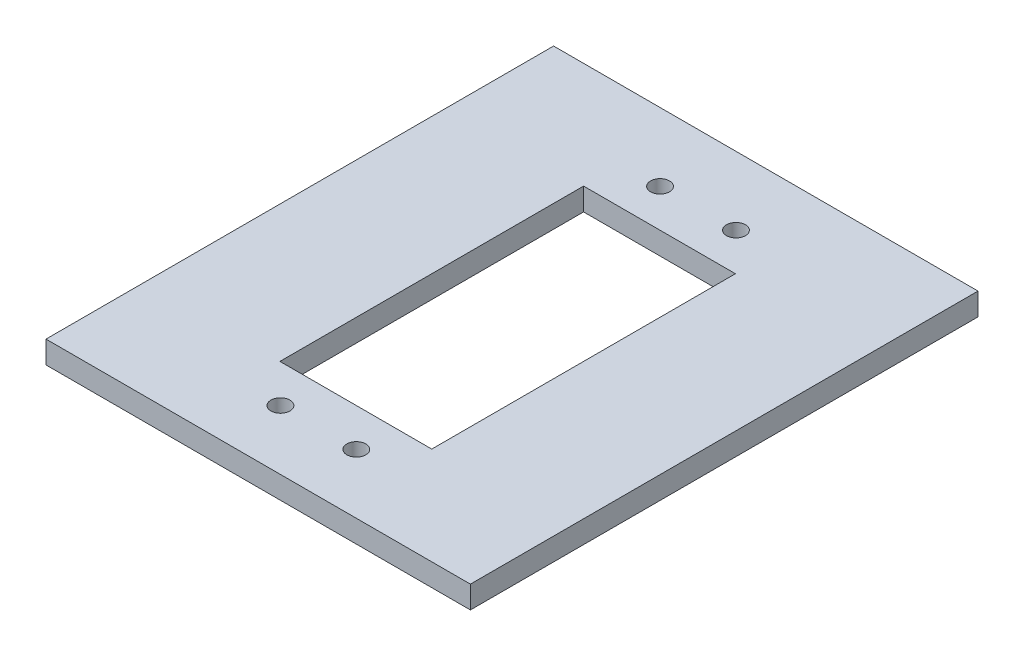
from build123d import *

# Parameters (mm, degrees)
SKETCH1_W           = 55.9
SKETCH1_H           = 66.86
BOSS_EXTRUDE1_DEPTH = 2.95
SKETCH3_W           = 20
SKETCH3_H           = 40
CUT_EXTRUDE1_DEPTH  = 6.86
SKETCH4_R           = 1.25
CUT_EXTRUDE2_DEPTH  = 6.86


with BuildPart() as part:
    # Sketch1 → Boss-Extrude1 (new body)
    with BuildSketch(Plane(origin=(0, 0, 0), x_dir=(1, 0, 0), z_dir=(0, 1, 0))):
        with Locations((3.202267267, 0.752730799)):
            Rectangle(SKETCH1_W, SKETCH1_H)
    extrude(amount=BOSS_EXTRUDE1_DEPTH)

    # Sketch3 → Cut-Extrude1 (cut)
    with BuildSketch(Plane(origin=(0, 2.95, 0), x_dir=(1, 0, 0), z_dir=(0, 1, 0))):
        with Locations((3.202267267, 0.182730799)):
            Rectangle(SKETCH3_W, SKETCH3_H)
    extrude(amount=-CUT_EXTRUDE1_DEPTH, mode=Mode.SUBTRACT)

    # Sketch4 → Cut-Extrude2 (cut)
    with BuildSketch(Plane(origin=(0, 2.95, 0), x_dir=(1, 0, 0), z_dir=(0, 1, 0))):
        with Locations((-1.729576987, 25.182730799)):
            Circle(SKETCH4_R)
        with Locations((8.270423013, 25.182730799)):
            Circle(SKETCH4_R)
        with Locations((-1.729576987, -24.817269201)):
            Circle(SKETCH4_R)
        with Locations((8.270423013, -24.817269201)):
            Circle(SKETCH4_R)
    extrude(amount=-CUT_EXTRUDE2_DEPTH, mode=Mode.SUBTRACT)


solid = part.part
